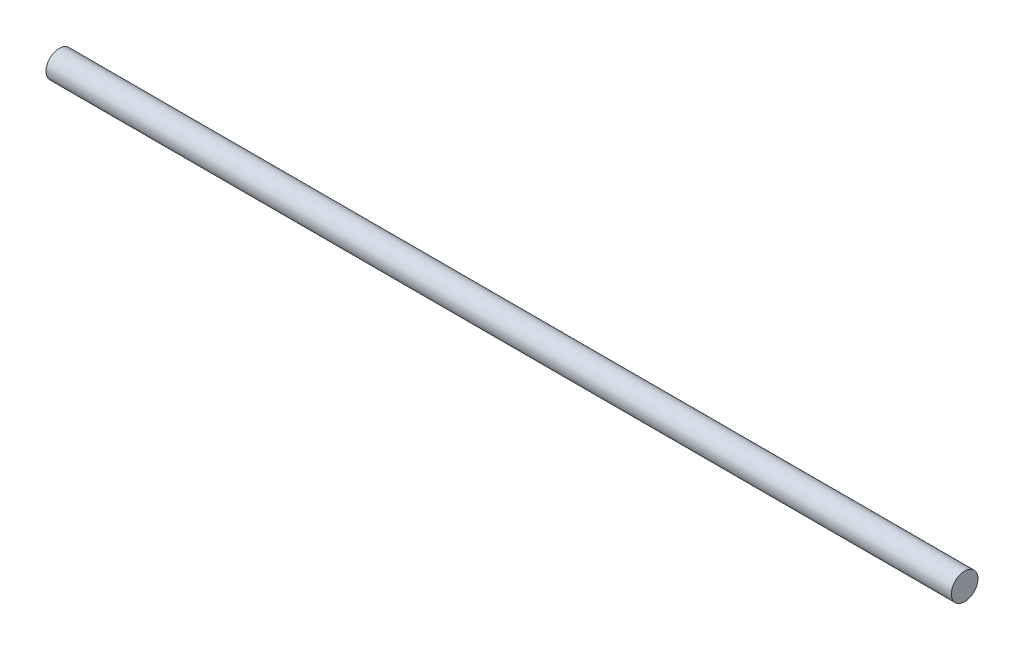
from build123d import *

# Parameters (mm, degrees)
SKETCH_1_R      = 60
EXTRUDE_1_DEPTH = 2040


with BuildPart() as part:
    # 草图1 → 凸台-拉伸1 (new body, symmetric)
    with BuildSketch(Plane(origin=(0, 0, 0), x_dir=(0, 0, -1), z_dir=(1, 0, 0))):
        Circle(SKETCH_1_R)
    extrude(amount=EXTRUDE_1_DEPTH, both=True)


solid = part.part
